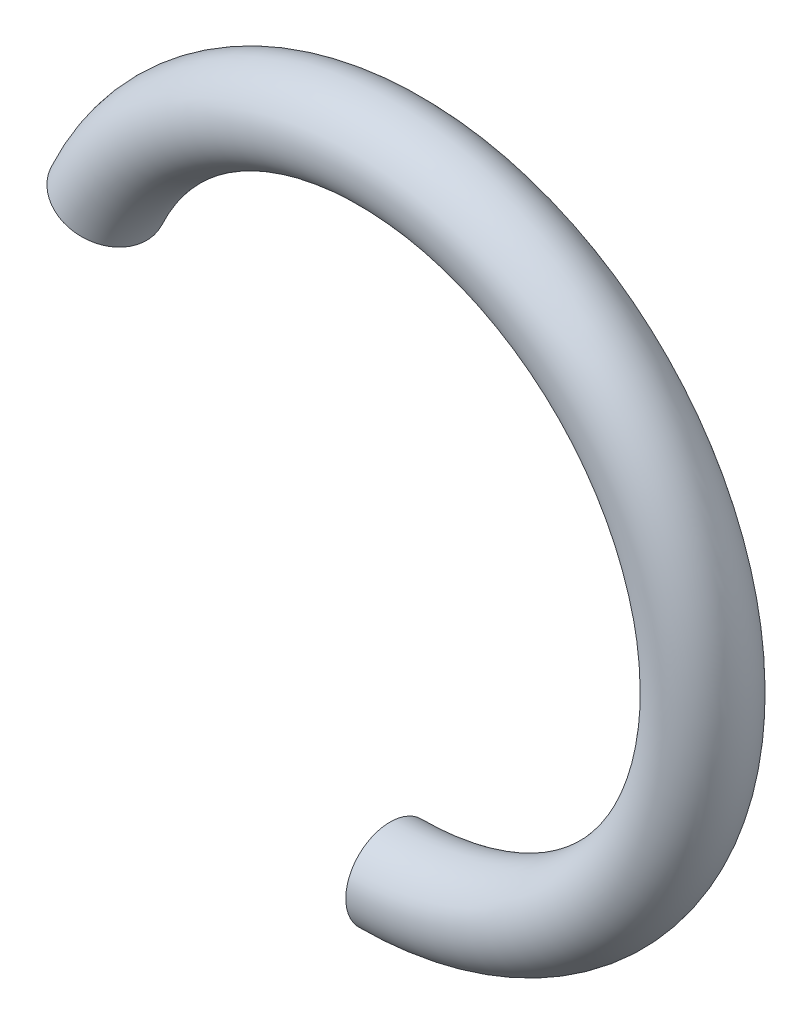
from build123d import *

# Parameters (mm, degrees)
SKETCH2_R = 0.65


with BuildPart() as part:
    # Sweep1: sweep along a path in Sketch1
    with BuildLine(Plane.XY) as sweep1_path:
        ThreePointArc((0, -4.6), (3.879600651, 2.471578198), (-4.16901582, 1.944044004))
    # Sketch2 → Sweep1 (sweep)
    with BuildSketch(Plane(origin=(0, 0, 0), x_dir=(0, 0, -1), z_dir=(1, 0, 0))):
        with Locations((0, -4.6)):
            Circle(SKETCH2_R)
    sweep(path=sweep1_path.line)


solid = part.part
